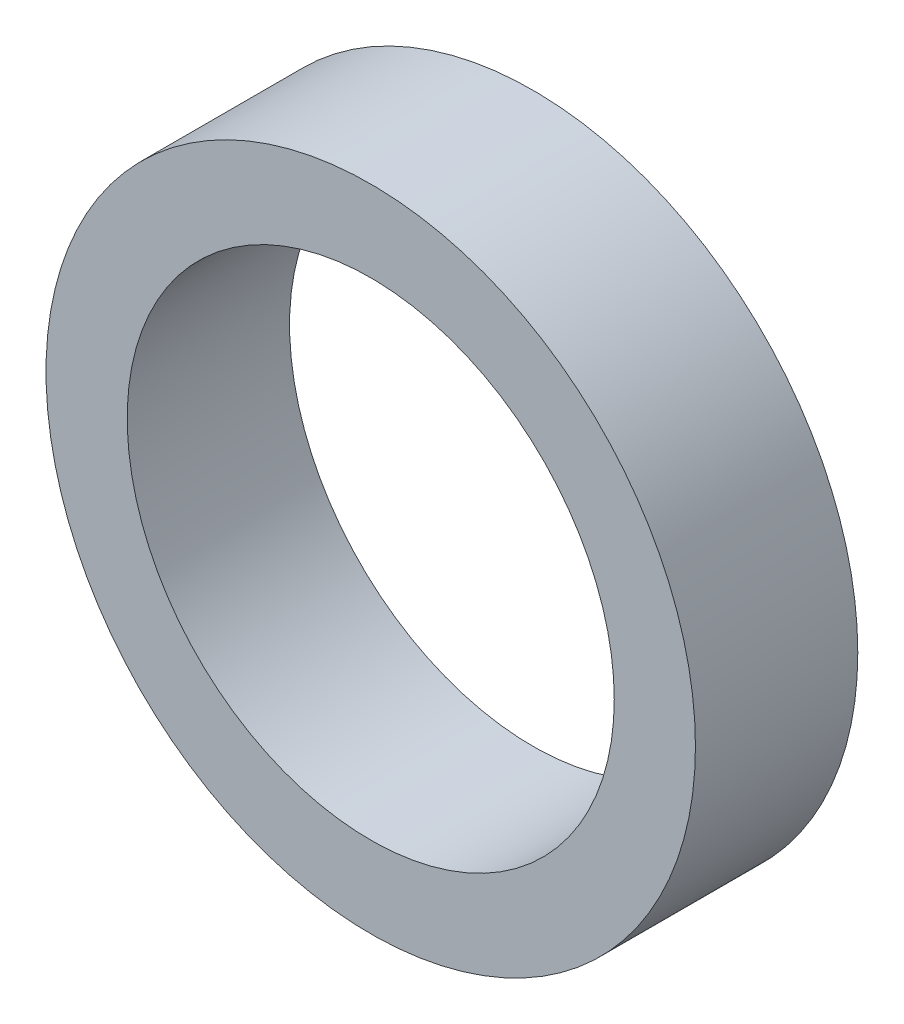
from build123d import *

# Parameters (mm, degrees)
SKETCH1_R           = 6.35
SKETCH1_R_2         = 4.7625
BOSS_EXTRUDE1_DEPTH = 3.175


with BuildPart() as part:
    # Sketch1 → Boss-Extrude1 (new body)
    with BuildSketch(Plane.XY):
        Circle(SKETCH1_R)
        Circle(SKETCH1_R_2, mode=Mode.SUBTRACT)
    extrude(amount=BOSS_EXTRUDE1_DEPTH)


solid = part.part
